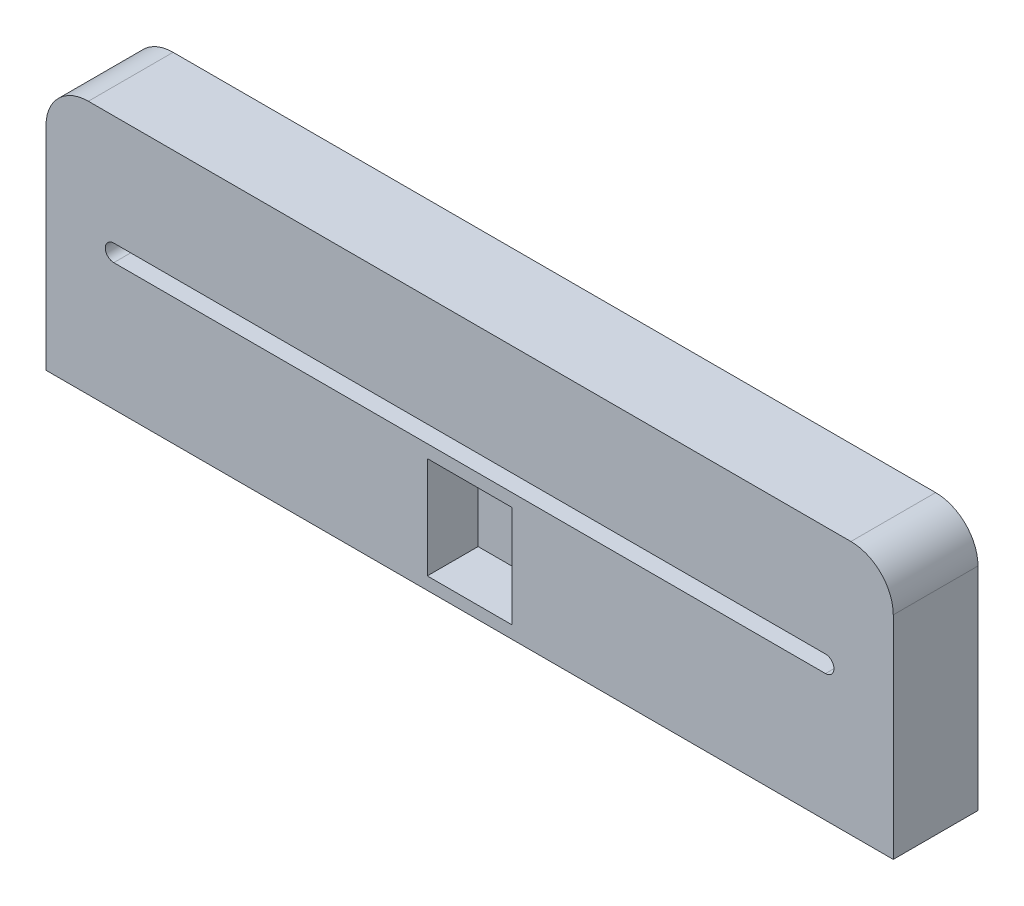
from build123d import *

# Parameters (mm, degrees)
CROQUIS1_W              = 50
CROQUIS1_H              = 15
SALIENTE_EXTRUIR1_DEPTH = 5
CROQUIS1_4_W            = 44
CROQUIS1_4_H            = 5
CORTAR_EXTRUIR1_DEPTH   = 2
REDONDEO1_R             = 2.5
CORTAR_EXTRUIR2_DEPTH   = 27.272609311
CROQUIS3_W              = 5
CROQUIS3_H              = 6
CORTAR_EXTRUIR3_DEPTH   = 3


with BuildPart() as part:
    # Croquis1 → Saliente-Extruir1 (new body)
    with BuildSketch(Plane.XY):
        Rectangle(CROQUIS1_W, CROQUIS1_H)
    extrude(amount=SALIENTE_EXTRUIR1_DEPTH)

    # Croquis1_4 → Cortar-Extruir1 (cut)
    with BuildSketch(Plane.XY):
        with Locations((0, 2)):
            Rectangle(CROQUIS1_4_W, CROQUIS1_4_H)
    extrude(amount=CORTAR_EXTRUIR1_DEPTH, mode=Mode.SUBTRACT)

    # Redondeo1
    redondeo1_edges = [part.edges().sort_by_distance(p)[0] for p in [
        (-25, 7.5, 2.5),
        (25, 7.5, 2.5),
    ]]
    fillet(redondeo1_edges, radius=REDONDEO1_R)

    # Croquis2 → Cortar-Extruir2 (cut, through all)
    with BuildSketch(Plane(origin=(0, 0, 2), x_dir=(-1, 0, 0), z_dir=(0, 0, -1))):
        with BuildLine():
            Line((-21, 1), (21, 1))
            ThreePointArc((21, 1), (21.5, 0.5), (21, 0))
            Line((21, 0), (-21, 0))
            ThreePointArc((-21, 0), (-21.5, 0.5), (-21, 1))
        make_face()
    extrude(amount=-CORTAR_EXTRUIR2_DEPTH, mode=Mode.SUBTRACT)

    # Croquis3 → Cortar-Extruir3 (cut)
    with BuildSketch(Plane.XY.offset(5)):
        with Locations((0, -3.760126058)):
            Rectangle(CROQUIS3_W, CROQUIS3_H)
    extrude(amount=-CORTAR_EXTRUIR3_DEPTH, mode=Mode.SUBTRACT)


solid = part.part
